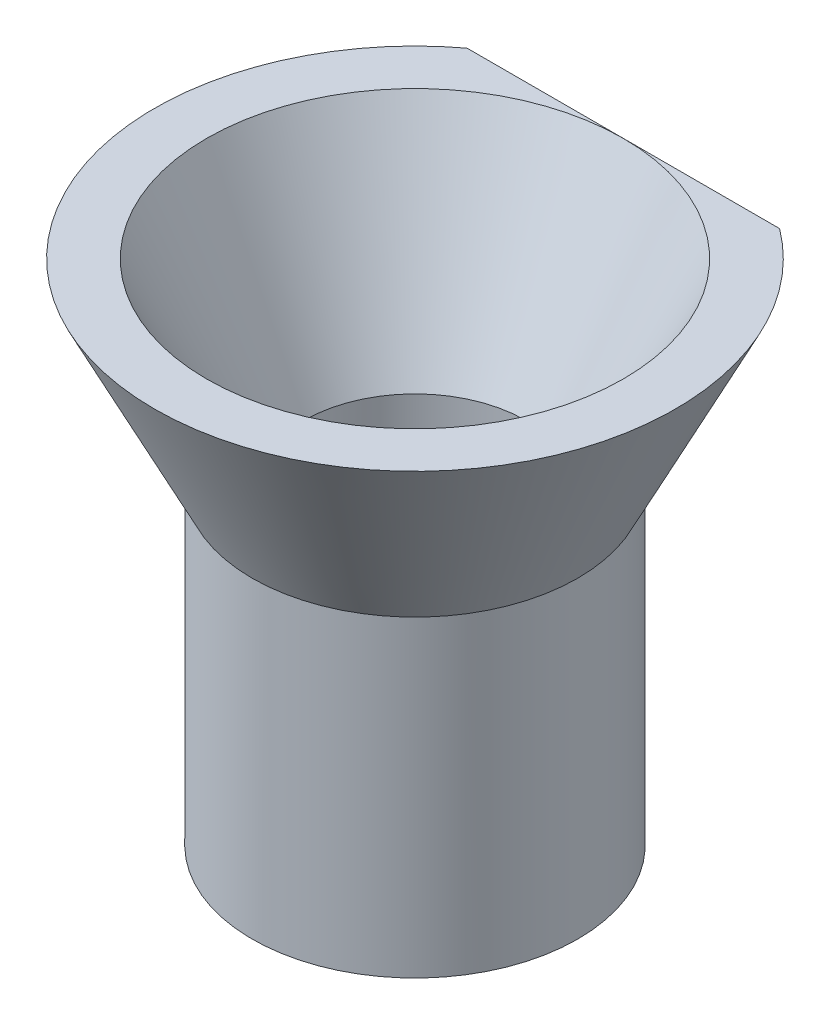
from build123d import *

# Parameters (mm, degrees)
CROQUIS3_R              = 6.25
CROQUIS3_R_2            = 4.25
SALIENTE_EXTRUIR1_DEPTH = 12
CORTAR_EXTRUIR1_DEPTH   = 10


with BuildPart() as part:
    # Croquis2 → Revolución1 (revolve)
    with BuildSketch(Plane.XY):
        Polygon((-4.25, 0), (-8, 7.5), (-10, 7.5), (-6.25, 0), align=None)
    revolve(axis=Axis((0, 7.5, 0), (0, -1, 0)))

    # Croquis3 → Saliente-Extruir1 (add)
    with BuildSketch(Plane.XZ):
        Circle(CROQUIS3_R)
        Circle(CROQUIS3_R_2, mode=Mode.SUBTRACT)
    extrude(amount=SALIENTE_EXTRUIR1_DEPTH)

    # Croquis4 → Cortar-Extruir1 (cut)
    with BuildSketch(Plane(origin=(0, 7.5, 0), x_dir=(1, 0, 0), z_dir=(0, 1, 0))):
        Polygon((-10.977061444, 8), (10.977061444, 8), (0, 12.60914387), align=None)
    extrude(amount=-CORTAR_EXTRUIR1_DEPTH, mode=Mode.SUBTRACT)


solid = part.part
